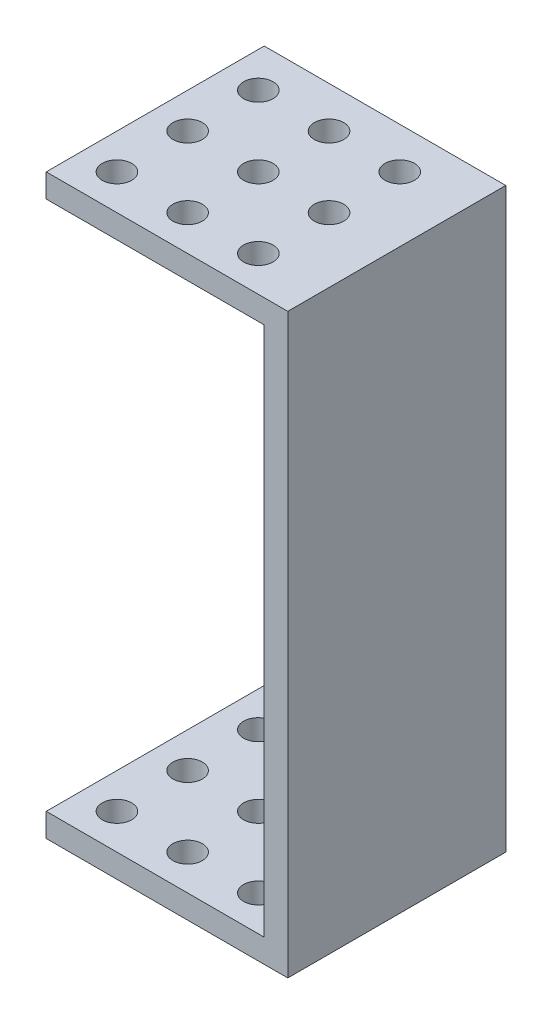
from build123d import *

# Parameters (mm, degrees)
SKETCH1_W            = 20.5
SKETCH1_H            = 18.5
BOSS_EXTRUDE1_DEPTH  = 2
SKETCH2_W            = 2
SKETCH2_H            = 18.5
BOSS_EXTRUDE2_DEPTH  = 45
SKETCH4_W            = 20.5
SKETCH4_H            = 18.5
BOSS_EXTRUDE3_DEPTH  = 2
SKETCH3_R            = 1.25
CUT_EXTRUDE1_DEPTH   = 50
LPATTERN1_COUNT      = 3
LPATTERN1_PITCH      = 6
LPATTERN1_COUNT_DIR2 = 3
LPATTERN1_PITCH_DIR2 = 6


with BuildPart() as part:
    # Sketch1 → Boss-Extrude1 (new body)
    with BuildSketch(Plane(origin=(0, 0, 0), x_dir=(1, 0, 0), z_dir=(0, 1, 0))):
        Rectangle(SKETCH1_W, SKETCH1_H)
    extrude(amount=BOSS_EXTRUDE1_DEPTH)

    # Sketch2 → Boss-Extrude2 (add)
    with BuildSketch(Plane(origin=(0, 2, 0), x_dir=(1, 0, 0), z_dir=(0, 1, 0))):
        with Locations((9.25, 0)):
            Rectangle(SKETCH2_W, SKETCH2_H)
    extrude(amount=BOSS_EXTRUDE2_DEPTH)

    # Sketch4 → Boss-Extrude3 (add)
    with BuildSketch(Plane(origin=(0, 47, 0), x_dir=(1, 0, 0), z_dir=(0, 1, 0))):
        Rectangle(SKETCH4_W, SKETCH4_H)
    extrude(amount=BOSS_EXTRUDE3_DEPTH)

    # Sketch3 → Cut-Extrude1 (cut, through all)
    with BuildSketch(Plane.XZ):
        with Locations((-7.25, 6.25)):
            Circle(SKETCH3_R)
    cut_extrude1 = extrude(amount=-CUT_EXTRUDE1_DEPTH, mode=Mode.SUBTRACT)

    # LPattern1: Cut-Extrude1 3 × 3
    with Locations(*[(j * LPATTERN1_PITCH_DIR2, 0, -i * LPATTERN1_PITCH) for i in range(LPATTERN1_COUNT) for j in range(LPATTERN1_COUNT_DIR2) if (i, j) != (0, 0)]):
        add(cut_extrude1, mode=Mode.SUBTRACT)


solid = part.part
